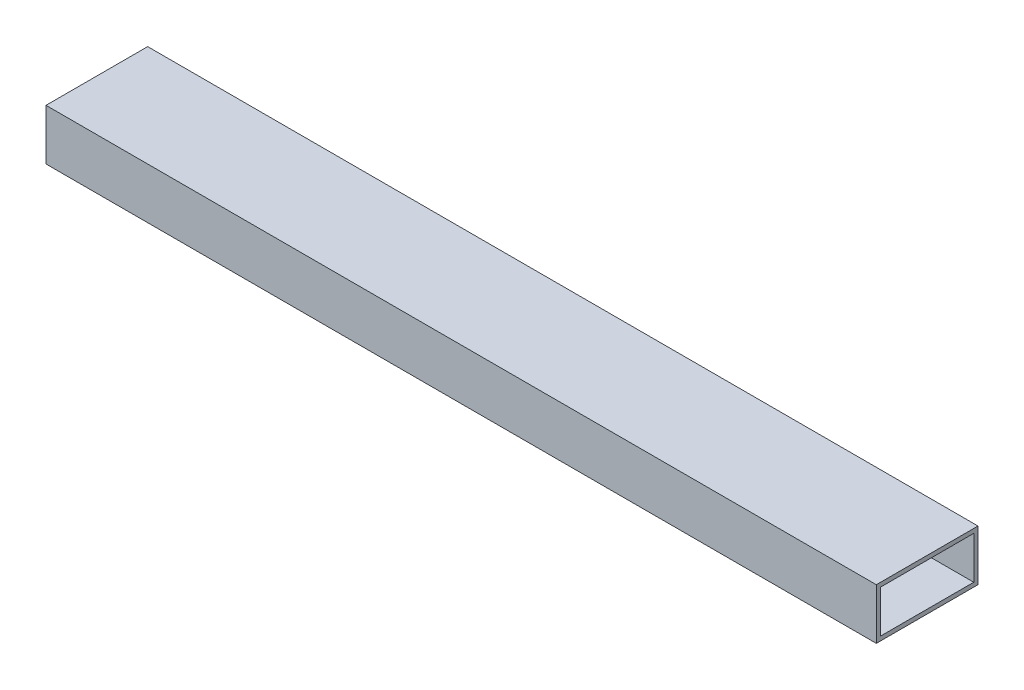
from build123d import *

# Parameters (mm, degrees)
SKETCH1_W                   = 76.2
SKETCH1_H                   = 38.1
SKETCH1_W_2                 = 69.85
SKETCH1_H_2                 = 31.75
BOSS_EXTRUDE1_DEPTH         = 311.15
F_1_4_20_TAPPED_HOLE1_D     = 5.1054
F_1_4_20_TAPPED_HOLE1_DEPTH = 3.175


with BuildPart() as part:
    # Sketch1 → Boss-Extrude1 (new body, symmetric)
    with BuildSketch(Plane(origin=(0, 0, 0), x_dir=(0, 0, -1), z_dir=(1, 0, 0))):
        with Locations((38.1, 19.05)):
            Rectangle(SKETCH1_W, SKETCH1_H)
        with Locations((38.1, 19.05)):
            Rectangle(SKETCH1_W_2, SKETCH1_H_2, mode=Mode.SUBTRACT)
    extrude(amount=BOSS_EXTRUDE1_DEPTH, both=True)

    # 1/4-20 Tapped Hole1
    with Locations(Plane(origin=(0, 0, -76.2), x_dir=(-1, 0, 0), z_dir=(0, 0, -1))):
        with Locations((260.35, 19.05), (-260.35, 19.05)):
            Hole(F_1_4_20_TAPPED_HOLE1_D / 2, depth=F_1_4_20_TAPPED_HOLE1_DEPTH)


solid = part.part
